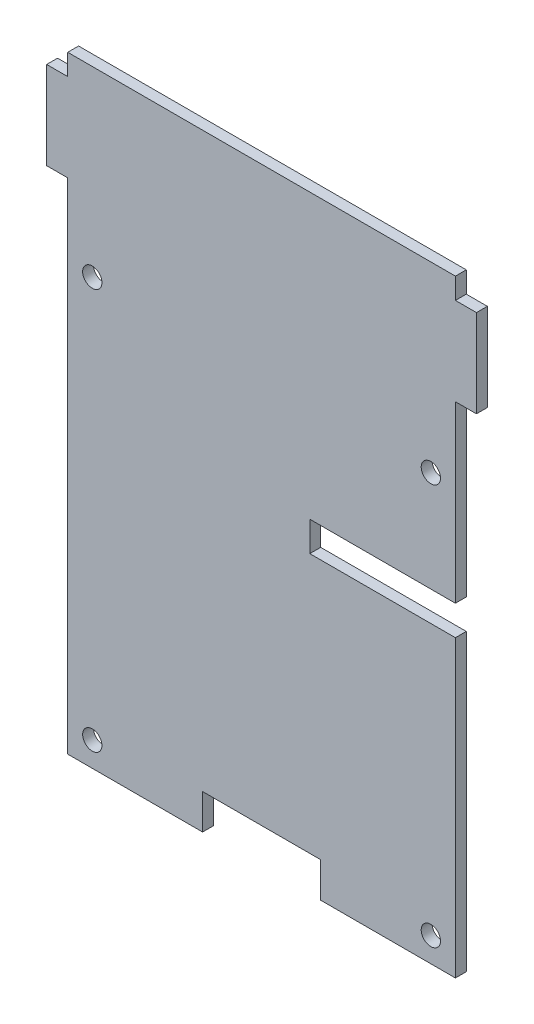
from build123d import *

# Parameters (mm, degrees)
BOSS_EXTRUDE1_DEPTH = 1.5748
SKETCH2_R           = 1.397
BOSS_EXTRUDE2_DEPTH = 1.5748


with BuildPart() as part:
    # Sketch1 → Boss-Extrude1 (new body)
    with BuildSketch(Plane.XY):
        Polygon((3.048, 84.963), (0, 84.963), (0, 88.011), (-56.134, 88.011), (-56.134, 84.963), (-59.182, 84.963), (-59.182, 72.263), (-56.134, 72.263), (-56.134, 64.77), (0, 64.77), (0, 72.263), (3.048, 72.263), align=None)
    extrude(amount=BOSS_EXTRUDE1_DEPTH)

    # Sketch2 → Boss-Extrude2 (add)
    with BuildSketch(Plane.XY.offset(1.5748)):
        Polygon((-36.6014, 0), (-36.6014, 5.08), (-19.558, 5.08), (-19.558, 0), (0, 0), (0, 42.672), (-21.082, 42.672), (-21.082, 46.99), (0, 46.99), (0, 64.77), (-56.134, 64.77), (-56.134, 0), align=None)
        with Locations((-52.578, 3.556)):
            Circle(SKETCH2_R, mode=Mode.SUBTRACT)
        with Locations((-3.556, 3.556)):
            Circle(SKETCH2_R, mode=Mode.SUBTRACT)
        with Locations((-52.578, 61.595)):
            Circle(SKETCH2_R, mode=Mode.SUBTRACT)
        with Locations((-3.556, 61.595)):
            Circle(SKETCH2_R, mode=Mode.SUBTRACT)
    extrude(amount=-BOSS_EXTRUDE2_DEPTH)


solid = part.part
